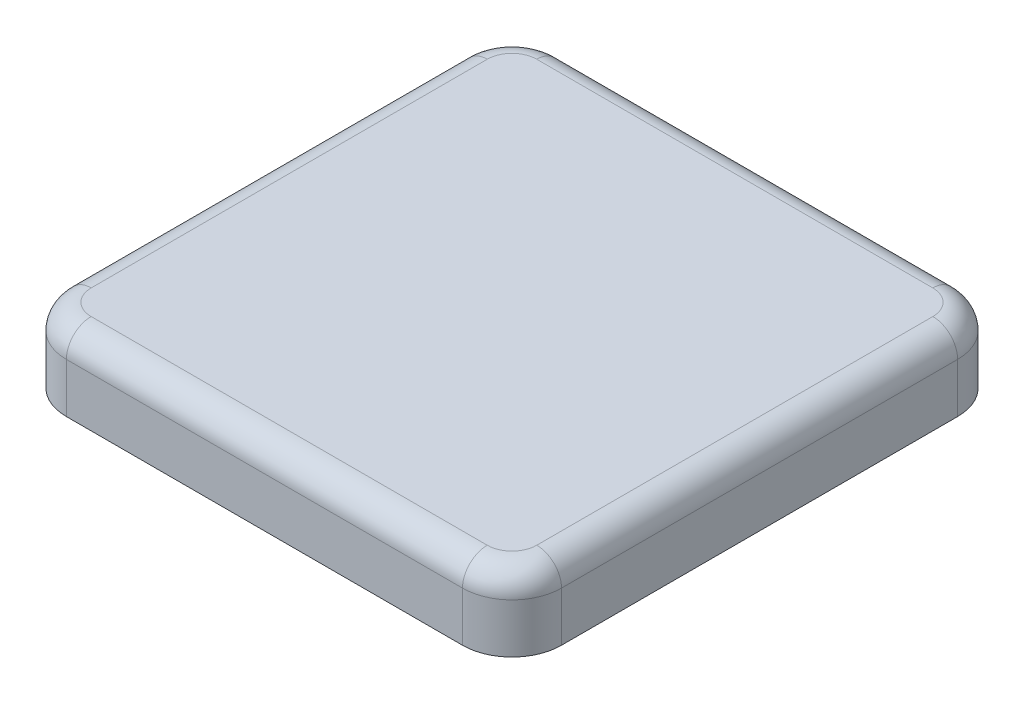
from build123d import *

# Parameters (mm, degrees)
SKETCH_1_W          = 5
SKETCH_1_H          = 5
EXTRUDE_1_DEPTH     = 2.5
SKETCH_2_W          = 4
SKETCH_2_H          = 4
CUT_EXTRUDE_1_DEPTH = 2.5
SKETCH_4_W          = 5
SKETCH_4_H          = 5
EXTRUDE_3_DEPTH     = 2
SKETCH_5_W          = 20
SKETCH_5_H          = 20
EXTRUDE_4_DEPTH     = 3
FILLET_6_R          = 2
FILLET_7_R          = 1


with BuildPart() as part:
    # 스케치1 → 보스-돌출1 (new body)
    with BuildSketch(Plane(origin=(0, 0, 0), x_dir=(1, 0, 0), z_dir=(0, 1, 0))):
        Rectangle(SKETCH_1_W, SKETCH_1_H)
    extrude(amount=EXTRUDE_1_DEPTH)

    # 스케치2 → 컷-돌출1 (cut)
    with BuildSketch(Plane(origin=(0, 2.5, 0), x_dir=(1, 0, 0), z_dir=(0, 1, 0))):
        Rectangle(SKETCH_2_W, SKETCH_2_H)
    extrude(amount=-CUT_EXTRUDE_1_DEPTH, mode=Mode.SUBTRACT)

    # 스케치4 → 보스-돌출3 (add)
    with BuildSketch(Plane(origin=(0, 2.5, 0), x_dir=(1, 0, 0), z_dir=(0, 1, 0))):
        Rectangle(SKETCH_4_W, SKETCH_4_H)
    extrude(amount=EXTRUDE_3_DEPTH)

    # 스케치5 → 보스-돌출4 (add)
    with BuildSketch(Plane(origin=(0, 4.5, 0), x_dir=(1, 0, 0), z_dir=(0, 1, 0))):
        Rectangle(SKETCH_5_W, SKETCH_5_H)
    extrude(amount=EXTRUDE_4_DEPTH)

    # 필렛6
    fillet_6_edges = [part.edges().sort_by_distance(p)[0] for p in [
        (10, 6, 10),
        (10, 6, -10),
        (-10, 6, -10),
        (-10, 6, 10),
    ]]
    fillet(fillet_6_edges, radius=FILLET_6_R)

    # 필렛7
    fillet_7_edges = [part.edges().sort_by_distance(p)[0] for p in [
        (-10, 7.5, 0),
        (0, 7.5, -10),
        (10, 7.5, 0),
        (0, 7.5, 10),
        (-9.414213562, 7.5, 9.414213562),
        (9.414213562, 7.5, 9.414213562),
        (9.414213562, 7.5, -9.414213562),
        (-9.414213562, 7.5, -9.414213562),
    ]]
    fillet(fillet_7_edges, radius=FILLET_7_R)


solid = part.part
